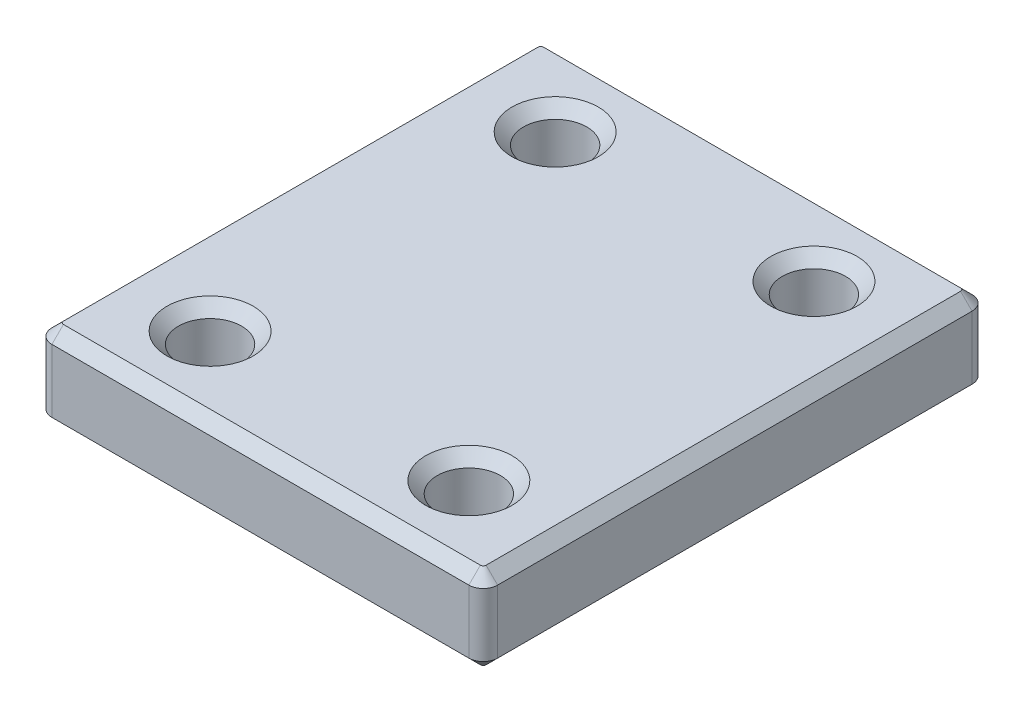
from build123d import *

# Parameters (mm, degrees)
SKETCH1_W           = 31
SKETCH1_H           = 35
BOSS_EXTRUDE1_DEPTH = 6
SKETCH2_R           = 2.2
CUT_EXTRUDE1_DEPTH  = 7
FILLET1_R           = 1
CHAMFER1_SIZE       = 0.8


with BuildPart() as part:
    # Sketch1 → Boss-Extrude1 (new body)
    with BuildSketch(Plane(origin=(0, 0, 0), x_dir=(1, 0, 0), z_dir=(0, 1, 0))):
        Rectangle(SKETCH1_W, SKETCH1_H)
    extrude(amount=BOSS_EXTRUDE1_DEPTH)

    # Sketch2 → Cut-Extrude1 (cut, through all)
    with BuildSketch(Plane(origin=(0, 6, 0), x_dir=(1, 0, 0), z_dir=(0, 1, 0))):
        with Locations((9, 12)):
            Circle(SKETCH2_R)
        with Locations((9, -12)):
            Circle(SKETCH2_R)
        with Locations((-9, 12)):
            Circle(SKETCH2_R)
        with Locations((-9, -12)):
            Circle(SKETCH2_R)
    extrude(amount=-CUT_EXTRUDE1_DEPTH, mode=Mode.SUBTRACT)

    # Fillet1
    fillet1_edges = [part.edges().sort_by_distance(p)[0] for p in [
        (15.5, 3, 17.5),
        (-15.5, 3, 17.5),
        (-15.5, 3, -17.5),
        (15.5, 3, -17.5),
    ]]
    fillet(fillet1_edges, radius=FILLET1_R)

    # Chamfer1
    chamfer1_edges = [part.edges().sort_by_distance(p)[0] for p in [
        (6.8, 0, 12),
        (6.8, 6, 12),
        (-11.2, 0, -12),
        (-11.2, 6, -12),
        (-11.2, 0, 12),
        (-11.2, 6, 12),
        (6.8, 0, -12),
        (6.8, 6, -12),
        (0, 0, 17.5),
        (0, 6, 17.5),
        (15.5, 0, 0),
        (-15.5, 0, 0),
        (0, 0, -17.5),
        (15.207106781, 0, 17.207106781),
        (15.207106781, 0, -17.207106781),
        (-15.207106781, 0, -17.207106781),
        (-15.207106781, 0, 17.207106781),
        (-15.5, 6, 0),
        (15.5, 6, 0),
        (0, 6, -17.5),
        (15.207106781, 6, 17.207106781),
        (15.207106781, 6, -17.207106781),
        (-15.207106781, 6, -17.207106781),
        (-15.207106781, 6, 17.207106781),
    ]]
    chamfer(chamfer1_edges, length=CHAMFER1_SIZE)


solid = part.part
